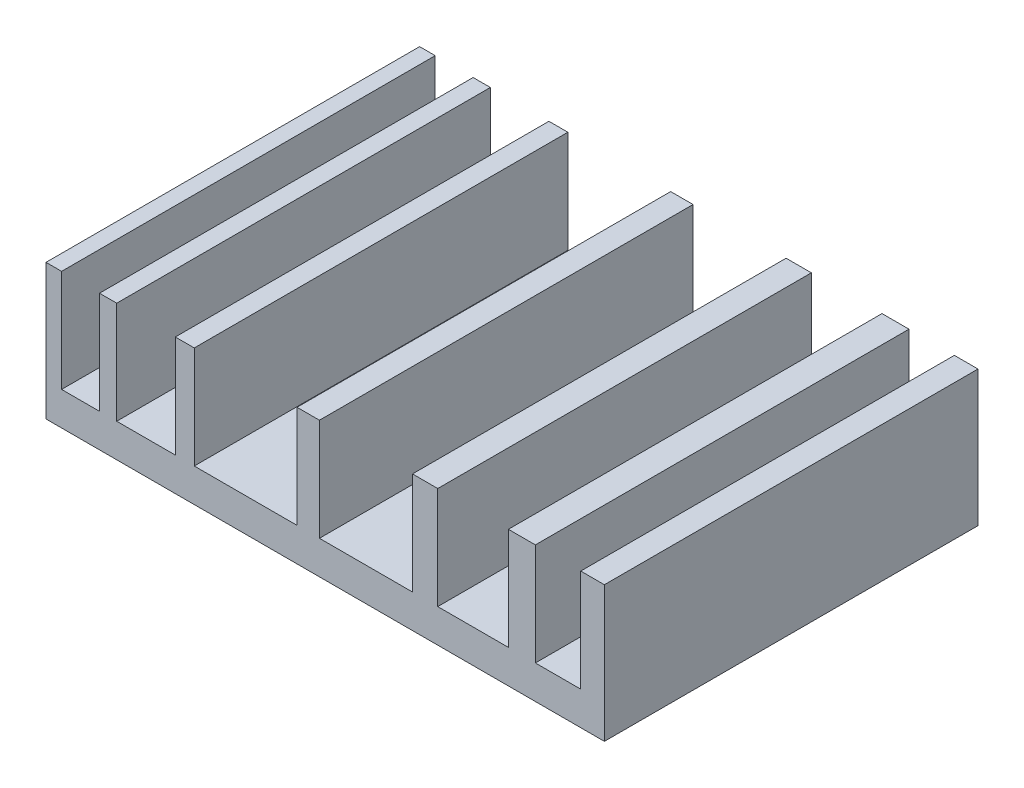
from build123d import *

# Parameters (mm, degrees)
SKETCH1_W           = 81.9
SKETCH1_H           = 54.8
BOSS_EXTRUDE1_DEPTH = 19.9
SKETCH3_W           = 8.59155047
SKETCH3_H           = 54.8
SKETCH3_W_2         = 15.077328766
SKETCH3_W_3         = 13.645403688
SKETCH3_W_4         = 10.360399097
SKETCH3_W_5         = 6.65424007
SKETCH3_W_6         = 5.559238539
CUT_EXTRUDE1_DEPTH  = 15


with BuildPart() as part:
    # Sketch1 → Boss-Extrude1 (new body)
    with BuildSketch(Plane(origin=(0, 0, 0), x_dir=(1, 0, 0), z_dir=(0, 1, 0))):
        with Locations((40.95, 27.4)):
            Rectangle(SKETCH1_W, SKETCH1_H)
    extrude(amount=BOSS_EXTRUDE1_DEPTH)

    # Sketch3 → Cut-Extrude1 (cut)
    with BuildSketch(Plane(origin=(0, 19.9, 0), x_dir=(1, 0, 0), z_dir=(0, 1, 0))):
        with Locations((14.669963268, 27.4)):
            Rectangle(SKETCH3_W, SKETCH3_H)
        with Locations((29.284022156, 27.4)):
            Rectangle(SKETCH3_W_2, SKETCH3_H)
        with Locations((46.930392974, 27.4)):
            Rectangle(SKETCH3_W_3, SKETCH3_H)
        with Locations((62.639453393, 27.4)):
            Rectangle(SKETCH3_W_4, SKETCH3_H)
        with Locations((75.105624663, 27.4)):
            Rectangle(SKETCH3_W_5, SKETCH3_H)
        with Locations((5.067642155, 27.4)):
            Rectangle(SKETCH3_W_6, SKETCH3_H)
    extrude(amount=-CUT_EXTRUDE1_DEPTH, mode=Mode.SUBTRACT)


solid = part.part
